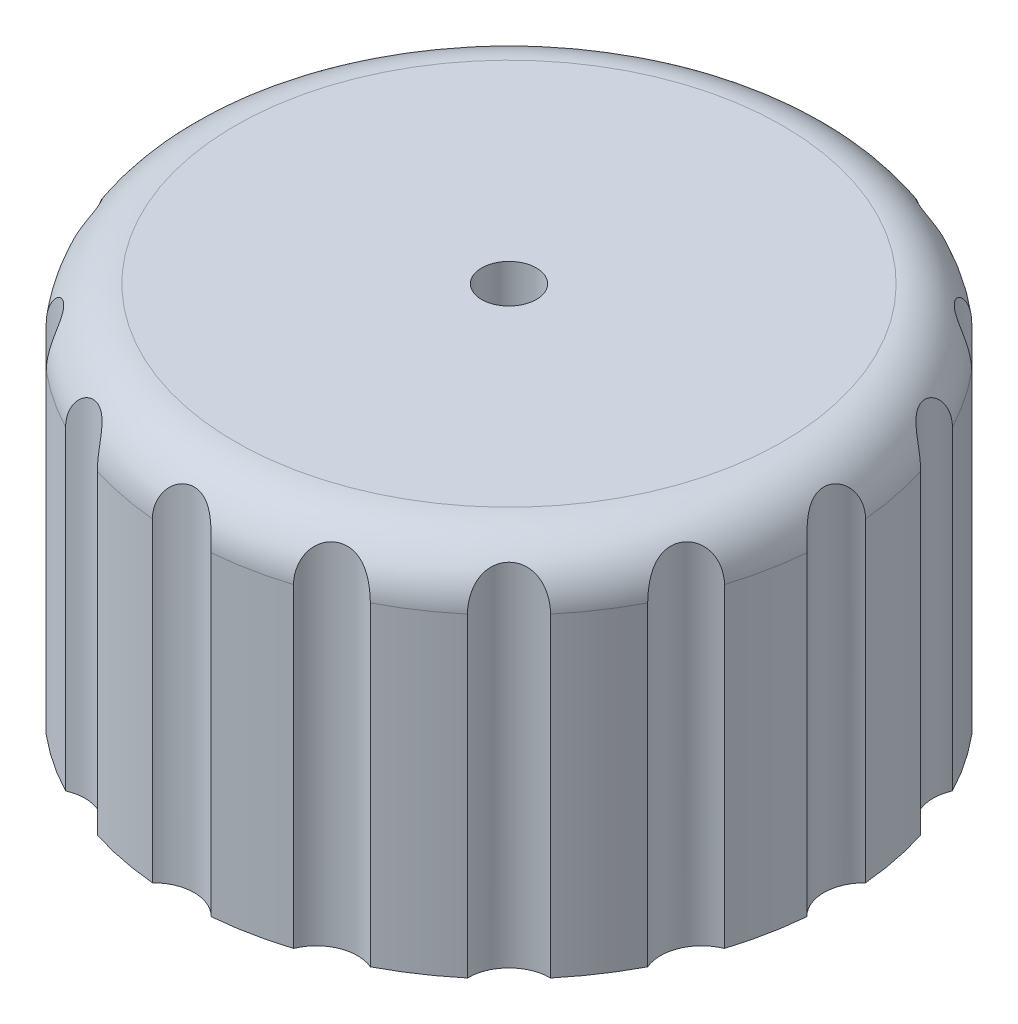
from build123d import *

# Parameters (mm, degrees)
FILLET1_R          = 1
SKETCH2_R          = 0.75
CUT_EXTRUDE1_DEPTH = 9
CIRPATTERN1_COUNT  = 16
SKETCH3_R          = 0.5
CUT_EXTRUDE2_DEPTH = 9.0000001


with BuildPart() as part:
    # Sketch1 → Revolve1 (revolve)
    with BuildSketch(Plane.XY):
        Polygon((-2.765, 0), (-2.765, 2.891054023), (0, 2.891054023), (0, 8), (-6, 8), (-6, 1.24483654), (-4.003398957, 1.24483654), (-3.067620744, 0), align=None)
    revolve(axis=Axis((0, 2.891054023, 0), (0, 1, 0)))

    # Fillet1
    fillet1_edges = [part.edges().sort_by_distance(p)[0] for p in [
        (6, 8, 0),
    ]]
    fillet(fillet1_edges, radius=FILLET1_R)

    # Sketch2 → Cut-Extrude1 (cut, through all)
    with BuildSketch(Plane(origin=(0, 0, 0), x_dir=(1, 0, 0), z_dir=(0, 1, 0))):
        with Locations((0, 6.5)):
            Circle(SKETCH2_R)
    cut_extrude1 = extrude(amount=CUT_EXTRUDE1_DEPTH, mode=Mode.SUBTRACT)

    # CirPattern1: Cut-Extrude1 ×16 about axis
    cirpattern1_axis = Axis((0, 0, 0), (0, 1, 0))
    for i in range(1, CIRPATTERN1_COUNT):
        add(cut_extrude1.rotate(cirpattern1_axis, i * 360 / CIRPATTERN1_COUNT), mode=Mode.SUBTRACT)

    # Sketch3 → Cut-Extrude2 (cut, through all)
    with BuildSketch(Plane(origin=(0, 0, 0), x_dir=(1, 0, 0), z_dir=(0, 1, 0))):
        Circle(SKETCH3_R)
    extrude(amount=CUT_EXTRUDE2_DEPTH, mode=Mode.SUBTRACT)


solid = part.part
